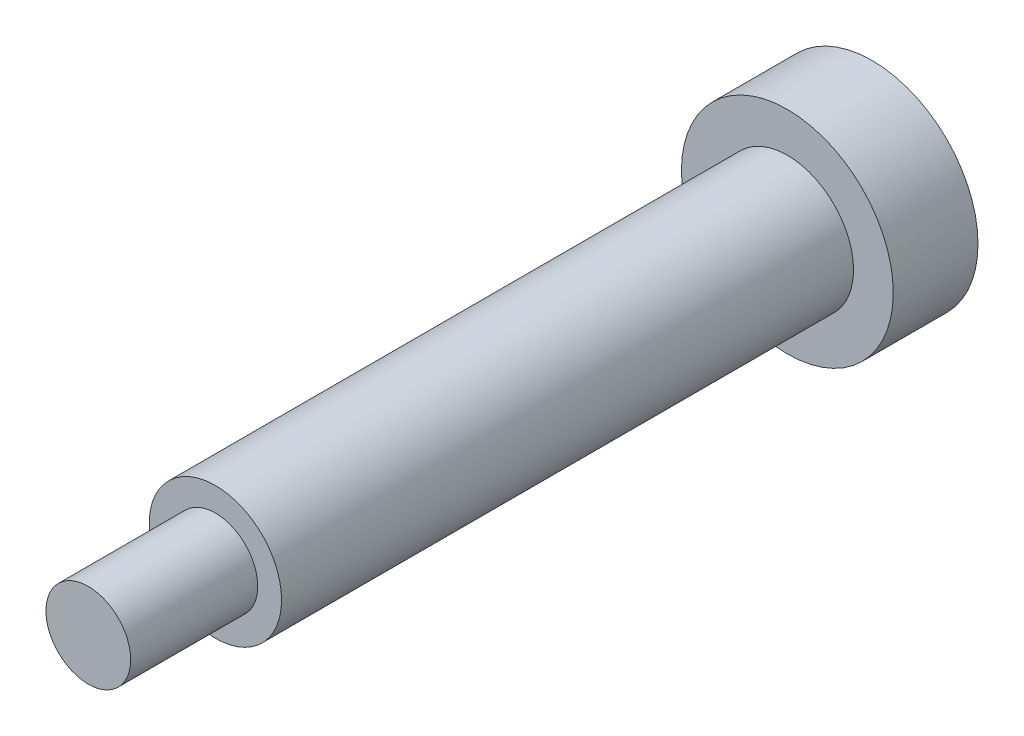
from build123d import *

# Parameters (mm, degrees)
SKETCH1_R           = 5
BOSS_EXTRUDE1_DEPTH = 4
SKETCH2_R           = 3.125
BOSS_EXTRUDE2_DEPTH = 27
SKETCH3_R           = 2
BOSS_EXTRUDE3_DEPTH = 6


with BuildPart() as part:
    # Sketch1 → Boss-Extrude1 (new body)
    with BuildSketch(Plane.XY):
        Circle(SKETCH1_R)
    extrude(amount=BOSS_EXTRUDE1_DEPTH)

    # Sketch2 → Boss-Extrude2 (add)
    with BuildSketch(Plane.XY.offset(4)):
        Circle(SKETCH2_R)
    extrude(amount=BOSS_EXTRUDE2_DEPTH)

    # Sketch3 → Boss-Extrude3 (add)
    with BuildSketch(Plane.XY.offset(31)):
        Circle(SKETCH3_R)
    extrude(amount=BOSS_EXTRUDE3_DEPTH)


solid = part.part
